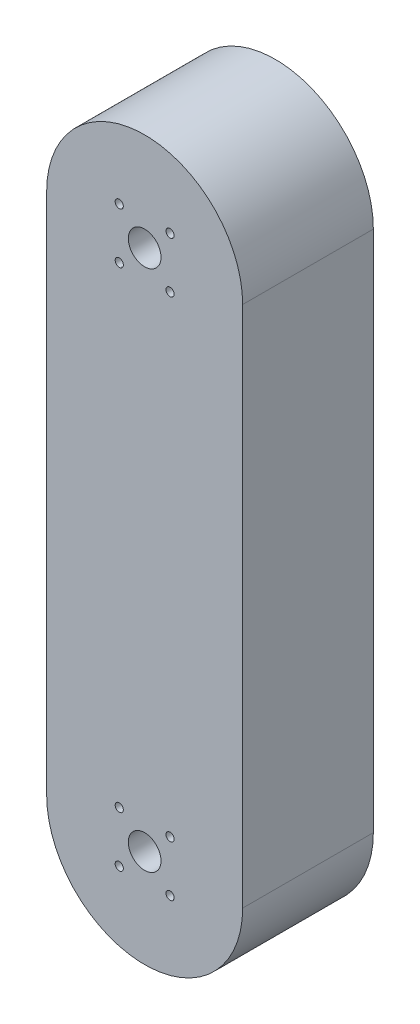
from build123d import *

# Parameters (mm, degrees)
BOSS_EXTRUDE1_DEPTH = 25.4
SKETCH2_R           = 3.175
SKETCH2_R_2         = 0.79375
CUT_EXTRUDE1_DEPTH  = 25.4


with BuildPart() as part:
    # Sketch1 → Boss-Extrude1 (new body)
    with BuildSketch(Plane.XY):
        with BuildLine():
            Line((19.05, 50.8), (19.05, -50.8))
            ThreePointArc((19.05, -50.8), (0, -69.85), (-19.05, -50.8))
            Line((-19.05, -50.8), (-19.05, 50.8))
            ThreePointArc((-19.05, 50.8), (0, 69.85), (19.05, 50.8))
        make_face()
    extrude(amount=BOSS_EXTRUDE1_DEPTH)

    # Sketch2 → Cut-Extrude1 (cut)
    with BuildSketch(Plane.XY.offset(25.4)):
        with Locations((0, 50.8)):
            Circle(SKETCH2_R)
        with Locations((-4.939140867, 55.739140867)):
            Circle(SKETCH2_R_2)
        with Locations((-4.939140867, 45.860859133)):
            Circle(SKETCH2_R_2)
        with Locations((4.939140867, 55.739140867)):
            Circle(SKETCH2_R_2)
        with Locations((4.939140867, 45.860859133)):
            Circle(SKETCH2_R_2)
    cut_extrude1 = extrude(amount=-CUT_EXTRUDE1_DEPTH, mode=Mode.SUBTRACT)

    # Mirror1: Cut-Extrude1 across plane
    add(cut_extrude1.mirror(Plane.ZX), mode=Mode.SUBTRACT)


solid = part.part
